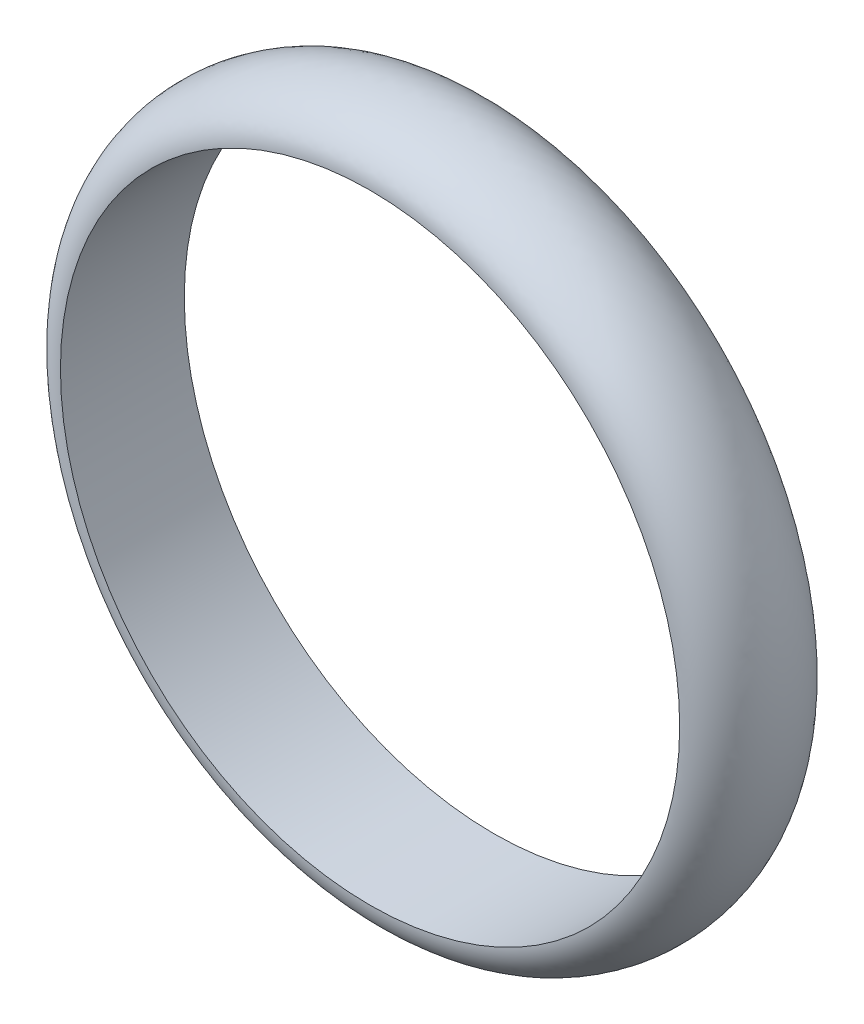
from build123d import *


with BuildPart() as part:
    # Esquisse1 → Révolution1 (revolve)
    with BuildSketch(Plane(origin=(0, 0, 0), x_dir=(0, 0, -1), z_dir=(1, 0, 0))):
        with BuildLine():
            Line((-10, 50), (10, 50))
            add(Edge.make_bspline(
                [(10, 50), (10, 57), (0, 57), (-10, 57), (-10, 50)],
                knots=[3.141592654, 3.141592654, 3.141592654, 4.71238898, 4.71238898, 6.283185307, 6.283185307, 6.283185307], degree=2, weights=[1, 0.707106781, 1, 0.707106781, 1]))
        make_face()
    revolve(axis=Axis((0, 0, 0), (0, 0, -1)))


solid = part.part
